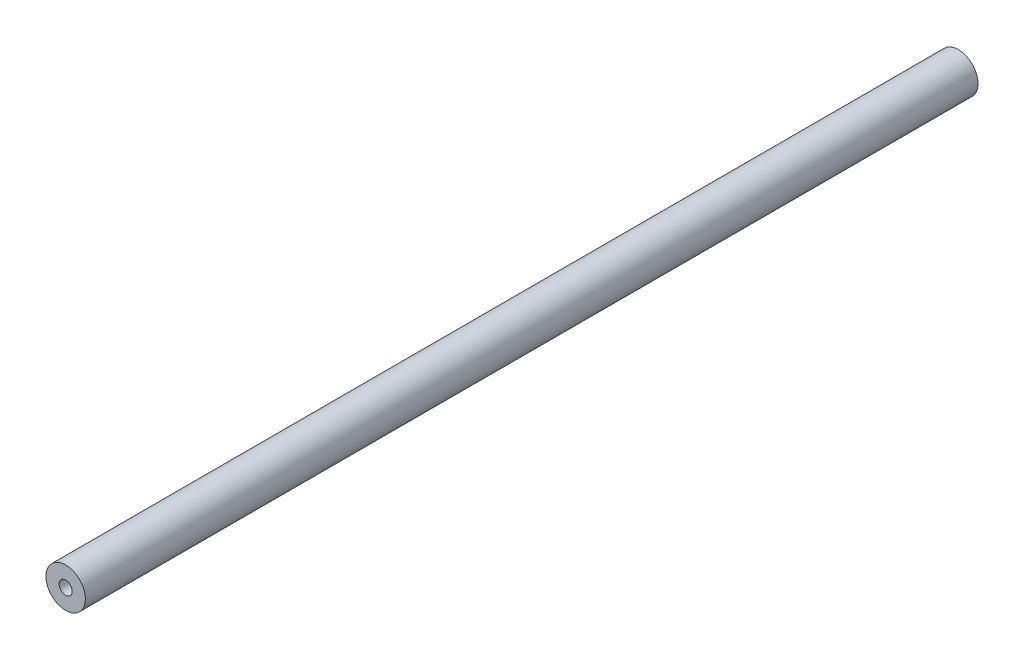
from build123d import *

# Parameters (mm, degrees)
SKETCH1_R           = 4.7625
SKETCH1_R_2         = 1.5875
BOSS_EXTRUDE1_DEPTH = 215.9


with BuildPart() as part:
    # Sketch1 → Boss-Extrude1 (new body)
    with BuildSketch(Plane.XY):
        Circle(SKETCH1_R)
        Circle(SKETCH1_R_2, mode=Mode.SUBTRACT)
    extrude(amount=BOSS_EXTRUDE1_DEPTH)


solid = part.part
